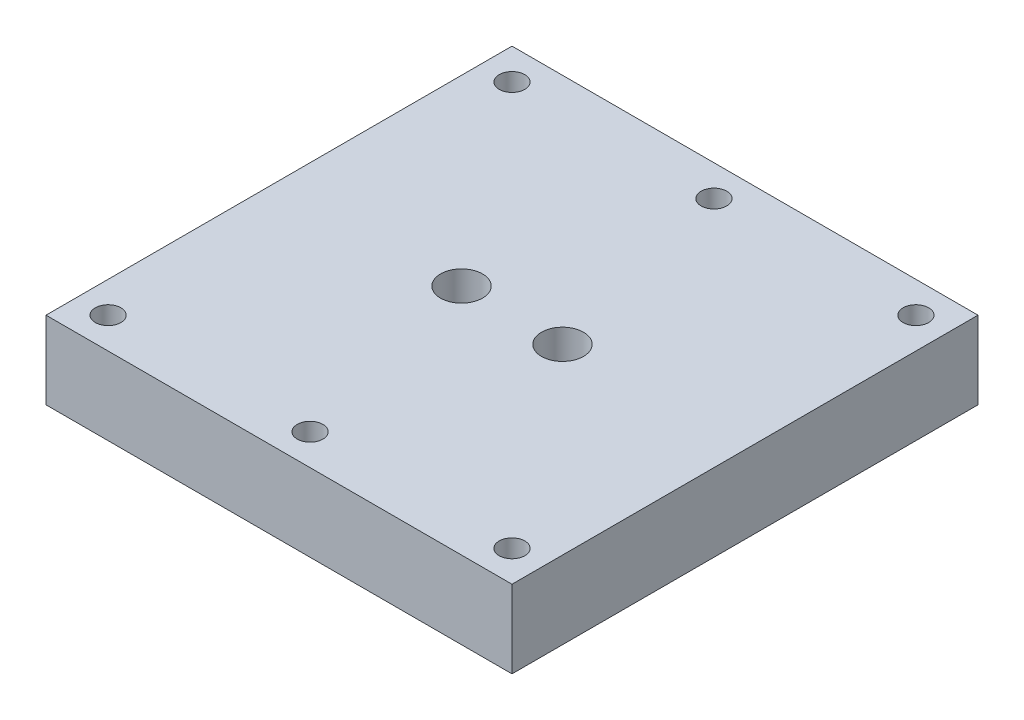
from build123d import *

# Parameters (mm, degrees)
SKETCH2_W                       = 60
SKETCH2_H                       = 60
BOSS_EXTRUDE1_DEPTH             = 10
TAP_DRILL_FOR_M4X0_7_TAP1_D     = 3.3
TAP_DRILL_FOR_M4X0_7_TAP1_DEPTH = 10
F_1_4_28_TAPPED_HOLE5_D         = 5.4102
F_1_4_28_TAPPED_HOLE5_DEPTH     = 7
F_1_4_28_TAPPED_HOLE5_TIP       = 1.625388061
F_1_0MM_DOWEL_HOLE1_D           = 1


with BuildPart() as part:
    # Sketch2 → Boss-Extrude1 (new body)
    with BuildSketch(Plane(origin=(0, 0, 0), x_dir=(1, 0, 0), z_dir=(0, 1, 0))):
        Rectangle(SKETCH2_W, SKETCH2_H)
    extrude(amount=BOSS_EXTRUDE1_DEPTH)

    # Tap Drill for M4x0.7 Tap1
    with Locations(Plane(origin=(0, 0, 0), x_dir=(-1, 0, 0), z_dir=(0, -1, 0))):
        with Locations((0, 26), (26, 26), (-26, 26), (-26, -26), (0, -26), (26, -26)):
            Hole(TAP_DRILL_FOR_M4X0_7_TAP1_D / 2, depth=TAP_DRILL_FOR_M4X0_7_TAP1_DEPTH)

    # 1/4-28 Tapped Hole5
    with Locations(Plane(origin=(0, 10, 0), x_dir=(-1, 0, 0), z_dir=(0, 1, 0))):
        with Locations((6.5, 0), (-6.5, 0)):
            Hole(F_1_4_28_TAPPED_HOLE5_D / 2, depth=F_1_4_28_TAPPED_HOLE5_DEPTH)
            with Locations((0, 0, -(F_1_4_28_TAPPED_HOLE5_DEPTH + F_1_4_28_TAPPED_HOLE5_TIP / 2))):  # 118° drill point
                Cone(0, F_1_4_28_TAPPED_HOLE5_D / 2, F_1_4_28_TAPPED_HOLE5_TIP, mode=Mode.SUBTRACT)

    # Ø1.0mm Dowel Hole1 (through all)
    with Locations(Plane(origin=(0, 10, 0), x_dir=(1, 0, 0), z_dir=(0, 1, 0))):
        with Locations((-6.5, 0), (6.5, 0)):
            Hole(F_1_0MM_DOWEL_HOLE1_D / 2)


solid = part.part
